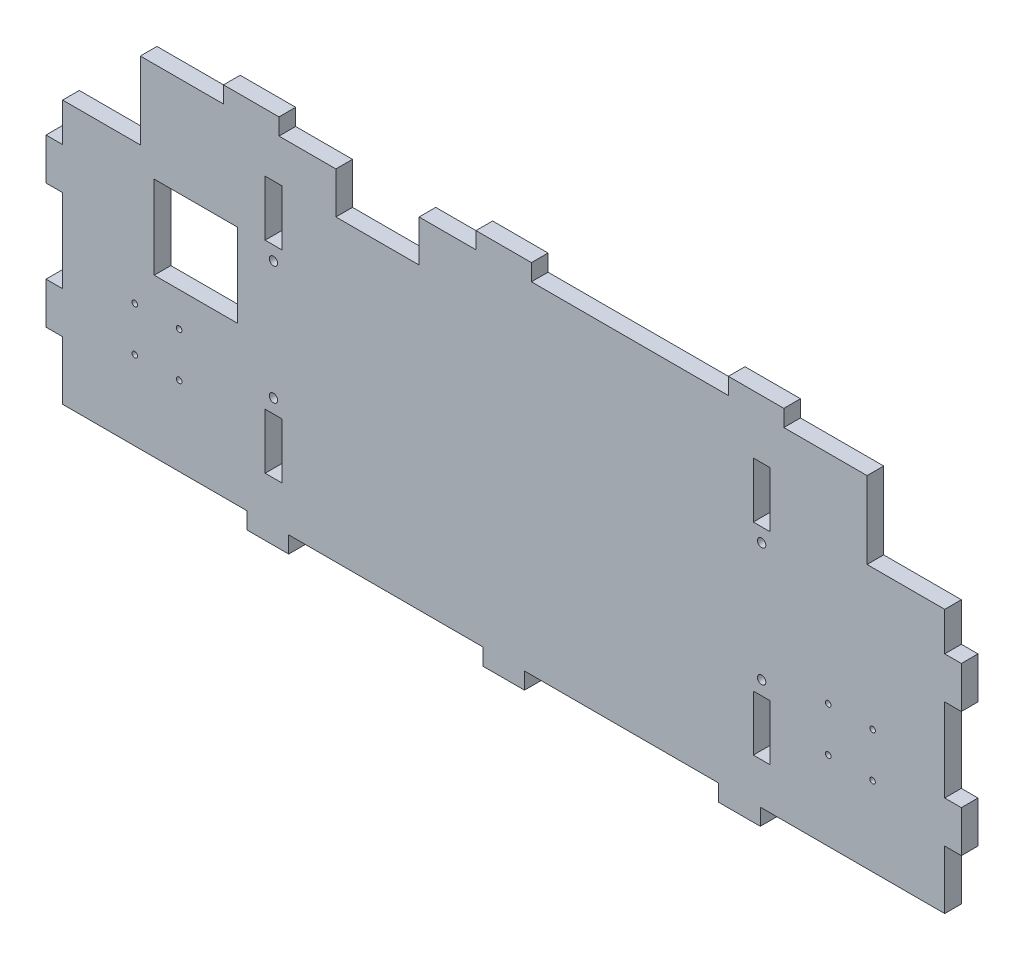
from build123d import *

# Parameters (mm, degrees)
ESQUISSE1_W             = 6
ESQUISSE1_H             = 20
ESQUISSE1_W_2           = 30
ESQUISSE1_H_2           = 30
BOSS_EXTRU_1_DEPTH      = 6
ESQUISSE2_W             = 15
ESQUISSE2_H             = 6
ESQUISSE2_W_2           = 6
ESQUISSE2_H_2           = 15
ESQUISSE2_W_3           = 20
BOSS_EXTRU_2_DEPTH      = 6
ESQUISSE3_R             = 1
ESQUISSE3_R_2           = 1.5
ENL_V_MAT_EXTRU_1_DEPTH = 6
ESQUISSE4_W             = 30
ESQUISSE4_H             = 15
ENL_V_MAT_EXTRU_2_DEPTH = 6


with BuildPart() as part:
    # Esquisse1 → Boss.-Extru.1 (new body)
    with BuildSketch(Plane.XY):
        Polygon((-159, 35), (-131, 35), (-131, 62.75), (131, 62.75), (131, 35), (159, 35), (159, -60), (-159, -60), align=None)
        with Locations((93, 37.75)):
            Rectangle(ESQUISSE1_W, ESQUISSE1_H, mode=Mode.SUBTRACT)
        with Locations((93, -35.01)):
            Rectangle(ESQUISSE1_W, ESQUISSE1_H, mode=Mode.SUBTRACT)
        with Locations((-83, 37.75)):
            Rectangle(ESQUISSE1_W, ESQUISSE1_H, mode=Mode.SUBTRACT)
        with Locations((-83, -35.01)):
            Rectangle(ESQUISSE1_W, ESQUISSE1_H, mode=Mode.SUBTRACT)
        with Locations((-110.986534361, 11.825583908)):
            Rectangle(ESQUISSE1_W_2, ESQUISSE1_H_2, mode=Mode.SUBTRACT)
    extrude(amount=BOSS_EXTRU_1_DEPTH)

    # Esquisse2 → Boss.-Extru.2 (add)
    with BuildSketch(Plane.XY.offset(6)):
        with Locations((-85, -63)):
            Rectangle(ESQUISSE2_W, ESQUISSE2_H)
        with Locations((0, -63)):
            Rectangle(ESQUISSE2_W, ESQUISSE2_H)
        with Locations((85, -63)):
            Rectangle(ESQUISSE2_W, ESQUISSE2_H)
        with Locations((-162, 13.59)):
            Rectangle(ESQUISSE2_W_2, ESQUISSE2_H_2)
        with Locations((-162, -31.41)):
            Rectangle(ESQUISSE2_W_2, ESQUISSE2_H_2)
        with Locations((162, -31.41)):
            Rectangle(ESQUISSE2_W_2, ESQUISSE2_H_2)
        with Locations((162, 13.59)):
            Rectangle(ESQUISSE2_W_2, ESQUISSE2_H_2)
        with Locations((91, 65.75)):
            Rectangle(ESQUISSE2_W_3, ESQUISSE2_H)
        with Locations((-91, 65.75)):
            Rectangle(ESQUISSE2_W_3, ESQUISSE2_H)
        with Locations((0, 65.75)):
            Rectangle(ESQUISSE2_W_3, ESQUISSE2_H)
    extrude(amount=-BOSS_EXTRU_2_DEPTH)

    # Esquisse3 → Enlèv. mat.-Extru.1 (cut)
    with BuildSketch(Plane(origin=(0, 0, 0), x_dir=(-1, 0, 0), z_dir=(0, 0, -1))):
        with Locations((133, -31.49)):
            Circle(ESQUISSE3_R)
        with Locations((133, -15.49)):
            Circle(ESQUISSE3_R)
        with Locations((117, -15.49)):
            Circle(ESQUISSE3_R)
        with Locations((117, -31.49)):
            Circle(ESQUISSE3_R)
        with Locations((-117, -31.49)):
            Circle(ESQUISSE3_R)
        with Locations((-117, -15.49)):
            Circle(ESQUISSE3_R)
        with Locations((-133, -15.49)):
            Circle(ESQUISSE3_R)
        with Locations((-133, -31.49)):
            Circle(ESQUISSE3_R)
        with Locations((83, 22.75)):
            Circle(ESQUISSE3_R_2)
        with Locations((83, -20.01)):
            Circle(ESQUISSE3_R_2)
        with Locations((-93, 22.75)):
            Circle(ESQUISSE3_R_2)
        with Locations((-93, -20.01)):
            Circle(ESQUISSE3_R_2)
    extrude(amount=-ENL_V_MAT_EXTRU_1_DEPTH, mode=Mode.SUBTRACT)

    # Esquisse4 → Enlèv. mat.-Extru.2 (cut)
    with BuildSketch(Plane(origin=(0, 0, 0), x_dir=(-1, 0, 0), z_dir=(0, 0, -1))):
        with Locations((45.5, 55.25)):
            Rectangle(ESQUISSE4_W, ESQUISSE4_H)
    extrude(amount=-ENL_V_MAT_EXTRU_2_DEPTH, mode=Mode.SUBTRACT)


solid = part.part
